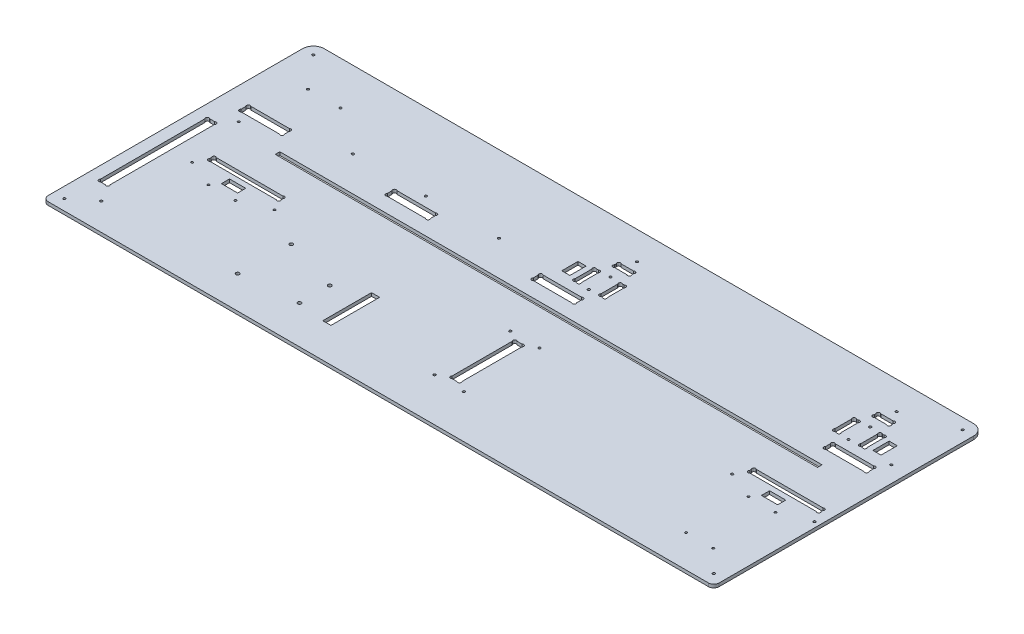
from build123d import *

# Parameters (mm, degrees)
ESQUISSE1_R             = 1.1
EXTRUSION1_DEPTH        = 3
ESQUISSE2_W             = 501
ESQUISSE2_H             = 4.2
ENL_V_MAT_EXTRU_1_DEPTH = 4
ESQUISSE3_R             = 1.1
ENL_V_MAT_EXTRU_2_DEPTH = 4
CONG_1_R                = 5
ESQUISSE4_R             = 1.1
ENL_V_MAT_EXTRU_3_DEPTH = 4
ESQUISSE5_R             = 1.59
ENL_V_MAT_EXTRU_4_DEPTH = 4
ESQUISSE6_W             = 15
ESQUISSE6_H             = 7.5
ESQUISSE6_W_2           = 7.5
ESQUISSE6_H_2           = 15
ESQUISSE6_H_3           = 45
ENL_V_MAT_EXTRU_5_DEPTH = 4
ESQUISSE7_R             = 1
ENL_V_MAT_EXTRU_6_DEPTH = 4
ESQUISSE8_R             = 1.1
ENL_V_MAT_EXTRU_7_DEPTH = 4


with BuildPart() as part:
    # Esquisse1 → Extrusion1 (new body)
    with BuildSketch(Plane(origin=(0, 0, 0), x_dir=(1, 0, 0), z_dir=(0, 1, 0))):
        with BuildLine():
            Line((10, 250), (610, 250))
            ThreePointArc((610, 250), (617.071067812, 247.071067812), (620, 240))
            Line((620, 240), (620, 0))
            Line((620, 0), (0, 0))
            Line((0, 0), (0, 240))
            ThreePointArc((0, 240), (2.928932188, 247.071067812), (10, 250))
        make_face()
        with Locations(Location((539, 98, 0), (0, 0, 270))):  # turned: the seam where the file's is
            Circle(ESQUISSE1_R, mode=Mode.SUBTRACT)
        with Locations(Location((615, 98, 0), (0, 0, 270))):  # turned: the seam where the file's is
            Circle(ESQUISSE1_R, mode=Mode.SUBTRACT)
        with BuildLine():
            Line((317, 211.2627417), (317, 212.7372583))
            ThreePointArc((317, 212.7372583), (317, 215), (319.2627417, 215))
            Line((319.2627417, 215), (330.7372583, 215))
            ThreePointArc((330.7372583, 215), (333, 215), (333, 212.7372583))
            Line((333, 212.7372583), (333, 211.2627417))
            ThreePointArc((333, 211.2627417), (333, 209), (330.737258301, 209))
            Line((330.737258301, 209), (319.262741699, 209))
            ThreePointArc((319.262741699, 209), (316.999999999, 209.000000001), (317, 211.2627417))
        make_face(mode=Mode.SUBTRACT)
        with BuildLine():
            Line((312.262741699, 179.5), (313.737258301, 179.5))
            ThreePointArc((313.737258301, 179.5), (316.000000001, 179.500000001), (316, 181.762741701))
            Line((316, 181.762741701), (316, 197.237258299))
            ThreePointArc((316, 197.237258299), (316.000000001, 199.499999999), (313.737258301, 199.5))
            Line((313.737258301, 199.5), (312.262741699, 199.5))
            ThreePointArc((312.262741699, 199.5), (309.999999999, 199.499999999), (310, 197.237258299))
            Line((310, 197.237258299), (310, 181.762741701))
            ThreePointArc((310, 181.762741701), (309.999999999, 179.500000001), (312.262741699, 179.5))
        make_face(mode=Mode.SUBTRACT)
        with BuildLine():
            Line((334, 181.762741701), (334, 197.2372583))
            ThreePointArc((334, 197.2372583), (334, 199.5), (336.2627417, 199.5))
            Line((336.2627417, 199.5), (337.7372583, 199.5))
            ThreePointArc((337.7372583, 199.5), (340, 199.5), (340, 197.2372583))
            Line((340, 197.2372583), (340, 181.762741701))
            ThreePointArc((340, 181.762741701), (340.000000001, 179.500000001), (337.737258301, 179.5))
            Line((337.737258301, 179.5), (336.262741699, 179.5))
            ThreePointArc((336.262741699, 179.5), (333.999999999, 179.500000001), (334, 181.762741701))
        make_face(mode=Mode.SUBTRACT)
        with BuildLine():
            Line((552.2627417, 179.5), (553.7372583, 179.5))
            ThreePointArc((553.7372583, 179.5), (556, 179.5), (556, 181.7627417))
            Line((556, 181.7627417), (556, 197.2372583))
            ThreePointArc((556, 197.2372583), (556, 199.5), (553.7372583, 199.5))
            Line((553.7372583, 199.5), (552.2627417, 199.5))
            ThreePointArc((552.2627417, 199.5), (550, 199.5), (550, 197.2372583))
            Line((550, 197.2372583), (550, 181.7627417))
            ThreePointArc((550, 181.7627417), (550, 179.5), (552.2627417, 179.5))
        make_face(mode=Mode.SUBTRACT)
        with BuildLine():
            Line((574, 181.7627417), (574, 197.2372583))
            ThreePointArc((574, 197.2372583), (574, 199.5), (576.2627417, 199.5))
            Line((576.2627417, 199.5), (577.7372583, 199.5))
            ThreePointArc((577.7372583, 199.5), (580, 199.5), (580, 197.2372583))
            Line((580, 197.2372583), (580, 181.7627417))
            ThreePointArc((580, 181.7627417), (580, 179.5), (577.7372583, 179.5))
            Line((577.7372583, 179.5), (576.2627417, 179.5))
            ThreePointArc((576.2627417, 179.5), (574, 179.5), (574, 181.7627417))
        make_face(mode=Mode.SUBTRACT)
        with BuildLine():
            Line((559.2627417, 209), (570.7372583, 209))
            ThreePointArc((570.7372583, 209), (573, 209), (573, 211.2627417))
            Line((573, 211.2627417), (573, 212.7372583))
            ThreePointArc((573, 212.7372583), (573, 215), (570.7372583, 215))
            Line((570.7372583, 215), (559.2627417, 215))
            ThreePointArc((559.2627417, 215), (557, 215), (557, 212.7372583))
            Line((557, 212.7372583), (557, 211.2627417))
            ThreePointArc((557, 211.2627417), (557, 209), (559.2627417, 209))
        make_face(mode=Mode.SUBTRACT)
        with BuildLine():
            Line((560, 167.7372583), (560, 163.2627417))
            ThreePointArc((560, 163.2627417), (560, 161), (562.2627417, 161))
            Line((562.2627417, 161), (597.7372583, 161))
            ThreePointArc((597.7372583, 161), (600, 161), (600, 163.2627417))
            Line((600, 163.2627417), (600, 167.7372583))
            ThreePointArc((600, 167.7372583), (600, 170), (597.7372583, 170))
            Line((597.7372583, 170), (562.2627417, 170))
            ThreePointArc((562.2627417, 170), (560, 170), (560, 167.7372583))
        make_face(mode=Mode.SUBTRACT)
        with BuildLine():
            Line((292.2627417, 161), (327.7372583, 161))
            ThreePointArc((327.7372583, 161), (330, 161), (330, 163.2627417))
            Line((330, 163.2627417), (330, 167.7372583))
            ThreePointArc((330, 167.7372583), (330, 170), (327.7372583, 170))
            Line((327.7372583, 170), (292.2627417, 170))
            ThreePointArc((292.2627417, 170), (290, 170), (290, 167.7372583))
            Line((290, 167.7372583), (290, 163.2627417))
            ThreePointArc((290, 163.2627417), (290, 161), (292.2627417, 161))
        make_face(mode=Mode.SUBTRACT)
        with BuildLine():
            Line((20, 167.7372583), (20, 163.2627417))
            ThreePointArc((20, 163.2627417), (20, 161), (22.2627417, 161))
            Line((22.2627417, 161), (57.7372583, 161))
            ThreePointArc((57.7372583, 161), (60, 161), (60, 163.2627417))
            Line((60, 163.2627417), (60, 167.7372583))
            ThreePointArc((60, 167.7372583), (60, 170), (57.7372583, 170))
            Line((57.7372583, 170), (22.2627417, 170))
            ThreePointArc((22.2627417, 170), (20, 170), (20, 167.7372583))
        make_face(mode=Mode.SUBTRACT)
        with BuildLine():
            Line((155, 167.7372583), (155, 163.2627417))
            ThreePointArc((155, 163.2627417), (155, 161), (157.2627417, 161))
            Line((157.2627417, 161), (192.7372583, 161))
            ThreePointArc((192.7372583, 161), (195, 161), (195, 163.2627417))
            Line((195, 163.2627417), (195, 167.7372583))
            ThreePointArc((195, 167.7372583), (195, 170), (192.7372583, 170))
            Line((192.7372583, 170), (157.2627417, 170))
            ThreePointArc((157.2627417, 170), (155, 170), (155, 167.7372583))
        make_face(mode=Mode.SUBTRACT)
        with BuildLine():
            Line((13.2627417, 40), (17.7372583, 40))
            ThreePointArc((17.7372583, 40), (20, 40), (20, 42.2627417))
            Line((20, 42.2627417), (20, 138.7372583))
            ThreePointArc((20, 138.7372583), (20, 141), (17.7372583, 141))
            Line((17.7372583, 141), (13.2627417, 141))
            ThreePointArc((13.2627417, 141), (11, 141), (11, 138.7372583))
            Line((11, 138.7372583), (11, 42.2627417))
            ThreePointArc((11, 42.2627417), (11, 40), (13.2627417, 40))
        make_face(mode=Mode.SUBTRACT)
        with BuildLine():
            Line((337.7372583, 45), (333.2627417, 45))
            ThreePointArc((333.2627417, 45), (331, 45), (331, 47.2627417))
            Line((331, 47.2627417), (331, 102.7372583))
            ThreePointArc((331, 102.7372583), (331, 105), (333.2627417, 105))
            Line((333.2627417, 105), (337.7372583, 105))
            ThreePointArc((337.7372583, 105), (340, 105), (340, 102.7372583))
            Line((340, 102.7372583), (340, 47.2627417))
            ThreePointArc((340, 47.2627417), (340, 45), (337.7372583, 45))
        make_face(mode=Mode.SUBTRACT)
        with BuildLine():
            Line((610, 109.2627417), (610, 110.7372583))
            ThreePointArc((610, 110.7372583), (610, 113), (607.7372583, 113))
            Line((607.7372583, 113), (546.2627417, 113))
            ThreePointArc((546.2627417, 113), (544, 113), (544, 110.7372583))
            Line((544, 110.7372583), (544, 109.2627417))
            ThreePointArc((544, 109.2627417), (544, 107), (546.2627417, 107))
            Line((546.2627417, 107), (607.7372583, 107))
            ThreePointArc((607.7372583, 107), (610, 107), (610, 109.2627417))
        make_face(mode=Mode.SUBTRACT)
        with BuildLine():
            Line((108.7372583, 113), (47.2627417, 113))
            ThreePointArc((47.2627417, 113), (45, 113), (45, 110.7372583))
            Line((45, 110.7372583), (45, 109.2627417))
            ThreePointArc((45, 109.2627417), (45, 107), (47.2627417, 107))
            Line((47.2627417, 107), (108.7372583, 107))
            ThreePointArc((108.7372583, 107), (111, 107), (111, 109.2627417))
            Line((111, 109.2627417), (111, 110.7372583))
            ThreePointArc((111, 110.7372583), (111, 113), (108.7372583, 113))
        make_face(mode=Mode.SUBTRACT)
    extrude(amount=EXTRUSION1_DEPTH)

    # Esquisse2 → Enlèv. mat.-Extru.1 (cut, through all)
    with BuildSketch(Plane(origin=(0, 3, 0), x_dir=(-1, 0, 0), z_dir=(0, 1, 0))):
        with Locations((-322.5, -144.9)):
            Rectangle(ESQUISSE2_W, ESQUISSE2_H)
    extrude(amount=-ENL_V_MAT_EXTRU_1_DEPTH, mode=Mode.SUBTRACT)

    # Esquisse3 → Enlèv. mat.-Extru.2 (cut, through all)
    with BuildSketch(Plane(origin=(0, 3, 0), x_dir=(1, 0, 0), z_dir=(0, 1, 0))):
        with Locations(Location((565, 179.5, 0), (0, 0, 270))):  # turned: the seam where the file's is
            Circle(ESQUISSE3_R)
        with Locations(Location((565, 199.5, 0), (0, 0, 270))):  # turned: the seam where the file's is
            Circle(ESQUISSE3_R)
        with Locations(Location((325, 179.5, 0), (0, 0, 270))):  # turned: the seam where the file's is
            Circle(ESQUISSE3_R)
        with Locations(Location((325, 199.5, 0), (0, 0, 270))):  # turned: the seam where the file's is
            Circle(ESQUISSE3_R)
    extrude(amount=-ENL_V_MAT_EXTRU_2_DEPTH, mode=Mode.SUBTRACT)

    # Congé1
    cong_1_edges = [part.edges().sort_by_distance(p)[0] for p in [
        (620, 1.5, 0),
        (0, 1.5, 0),
    ]]
    fillet(cong_1_edges, radius=CONG_1_R)

    # Esquisse4 → Enlèv. mat.-Extru.3 (cut, through all)
    with BuildSketch(Plane.XZ):
        with Locations(Location((10, -10, 0), (0, 0, 270))):  # turned: the seam where the file's is
            Circle(ESQUISSE4_R)
        with Locations(Location((610, -10, 0), (0, 0, 270))):  # turned: the seam where the file's is
            Circle(ESQUISSE4_R)
        with Locations(Location((610, -240, 0), (0, 0, 270))):  # turned: the seam where the file's is
            Circle(ESQUISSE4_R)
        with Locations(Location((10, -240, 0), (0, 0, 270))):  # turned: the seam where the file's is
            Circle(ESQUISSE4_R)
    extrude(amount=-ENL_V_MAT_EXTRU_3_DEPTH, mode=Mode.SUBTRACT)

    # Esquisse5 → Enlèv. mat.-Extru.4 (cut, through all)
    with BuildSketch(Plane(origin=(0, 3, 0), x_dir=(1, 0, 0), z_dir=(0, 1, 0))):
        with Locations(Location((151.27, 78.26, 0), (0, 0, 270))):  # turned: the seam where the file's is
            Circle(ESQUISSE5_R)
        with Locations(Location((150, 30, 0), (0, 0, 270))):  # turned: the seam where the file's is
            Circle(ESQUISSE5_R)
        with Locations(Location((202.07, 63.02, 0), (0, 0, 270))):  # turned: the seam where the file's is
            Circle(ESQUISSE5_R)
        with Locations(Location((202.07, 35.08, 0), (0, 0, 270))):  # turned: the seam where the file's is
            Circle(ESQUISSE5_R)
    extrude(amount=-ENL_V_MAT_EXTRU_4_DEPTH, mode=Mode.SUBTRACT)

    # Esquisse6 → Enlèv. mat.-Extru.5 (cut, through all)
    with BuildSketch(Plane(origin=(0, 3, 0), x_dir=(1, 0, 0), z_dir=(0, 1, 0))):
        with Locations((577, 98.25)):
            Rectangle(ESQUISSE6_W, ESQUISSE6_H)
        with Locations((588.75, 189.5)):
            Rectangle(ESQUISSE6_W_2, ESQUISSE6_H_2)
        with Locations((301.25, 189.5)):
            Rectangle(ESQUISSE6_W_2, ESQUISSE6_H_2)
        with Locations((230.82, 54.13)):
            Rectangle(ESQUISSE6_W_2, ESQUISSE6_H_3)
        with Locations((78, 98.25)):
            Rectangle(ESQUISSE6_W, ESQUISSE6_H)
    extrude(amount=-ENL_V_MAT_EXTRU_5_DEPTH, mode=Mode.SUBTRACT)

    # Esquisse7 → Enlèv. mat.-Extru.6 (cut, through all)
    with BuildSketch(Plane(origin=(0, 3, 0), x_dir=(1, 0, 0), z_dir=(0, 1, 0))):
        with Locations(Location((589.5, 87.5, 0), (0, 0, 270))):  # turned: the seam where the file's is
            Circle(ESQUISSE7_R)
        with Locations(Location((564.5, 87.5, 0), (0, 0, 270))):  # turned: the seam where the file's is
            Circle(ESQUISSE7_R)
        with Locations(Location((65.5, 87.5, 0), (0, 0, 270))):  # turned: the seam where the file's is
            Circle(ESQUISSE7_R)
        with Locations(Location((90.5, 87.5, 0), (0, 0, 270))):  # turned: the seam where the file's is
            Circle(ESQUISSE7_R)
        with Locations(Location((116, 98, 0), (0, 0, 270))):  # turned: the seam where the file's is
            Circle(ESQUISSE7_R)
        with Locations(Location((40, 98, 0), (0, 0, 270))):  # turned: the seam where the file's is
            Circle(ESQUISSE7_R)
        with Locations(Location((564.5, 30, 0), (0, 0, 270))):  # turned: the seam where the file's is
            Circle(ESQUISSE7_R)
        with Locations(Location((589.5, 30, 0), (0, 0, 270))):  # turned: the seam where the file's is
            Circle(ESQUISSE7_R)
    extrude(amount=-ENL_V_MAT_EXTRU_6_DEPTH, mode=Mode.SUBTRACT)

    # Esquisse8 → Enlèv. mat.-Extru.7 (cut, through all)
    with BuildSketch(Plane(origin=(0, 3, 0), x_dir=(1, 0, 0), z_dir=(0, 1, 0))):
        with Locations(Location((29, 25, 0), (0, 0, 270))):  # turned: the seam where the file's is
            Circle(ESQUISSE8_R)
        with Locations(Location((29, 152, 0), (0, 0, 270))):  # turned: the seam where the file's is
            Circle(ESQUISSE8_R)
        with Locations(Location((107.5, 179, 0), (0, 0, 270))):  # turned: the seam where the file's is
            Circle(ESQUISSE8_R)
        with Locations(Location((242.5, 179, 0), (0, 0, 270))):  # turned: the seam where the file's is
            Circle(ESQUISSE8_R)
        with Locations(Location((175, 179, 0), (0, 0, 270))):  # turned: the seam where the file's is
            Circle(ESQUISSE8_R)
        with Locations(Location((325, 224, 0), (0, 0, 270))):  # turned: the seam where the file's is
            Circle(ESQUISSE8_R)
        with Locations(Location((565, 224, 0), (0, 0, 270))):  # turned: the seam where the file's is
            Circle(ESQUISSE8_R)
        with Locations(Location((605, 179, 0), (0, 0, 270))):  # turned: the seam where the file's is
            Circle(ESQUISSE8_R)
        with Locations(Location((35, 210, 0), (0, 0, 270))):  # turned: the seam where the file's is
            Circle(ESQUISSE8_R)
        with Locations(Location((322, 40, 0), (0, 0, 270))):  # turned: the seam where the file's is
            Circle(ESQUISSE8_R)
        with Locations(Location((322, 110, 0), (0, 0, 270))):  # turned: the seam where the file's is
            Circle(ESQUISSE8_R)
        with Locations(Location((349, 110, 0), (0, 0, 270))):  # turned: the seam where the file's is
            Circle(ESQUISSE8_R)
        with Locations(Location((349, 40, 0), (0, 0, 270))):  # turned: the seam where the file's is
            Circle(ESQUISSE8_R)
        with Locations(Location((65, 210, 0), (0, 0, 270))):  # turned: the seam where the file's is
            Circle(ESQUISSE8_R)
    extrude(amount=-ENL_V_MAT_EXTRU_7_DEPTH, mode=Mode.SUBTRACT)


solid = part.part
